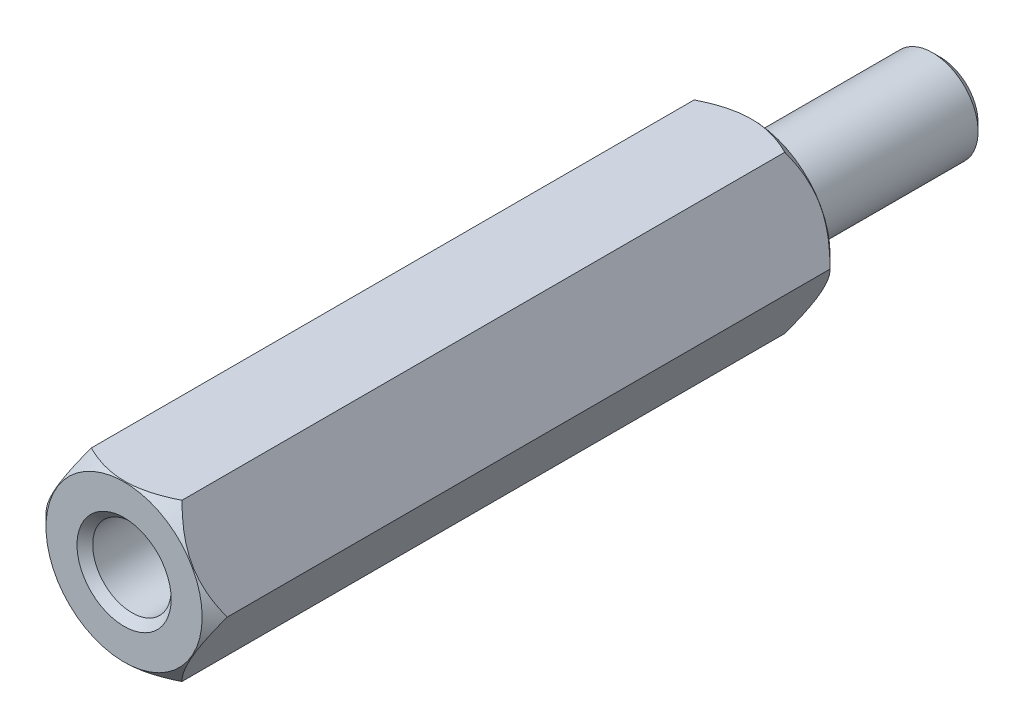
from build123d import *

# Parameters (mm, degrees)
HEX_2_DEPTH                 = 10
TAP_DRILL_FOR_M3X0_5_TAP1_D = 2.5
SKETCH8_R                   = 1.45
THREAD_DEPTH                = 6
THREAD_DEPTH_BACK           = 2
INNERCHAMFER_SIZE           = 0.25


with BuildPart() as part:
    # Sketch1 → HEX 2 (new body, symmetric)
    with BuildSketch(Plane.XY):
        Polygon((2.886751346, 0), (1.443375673, 2.5), (-1.443375673, 2.5), (-2.886751346, 0), (-1.443375673, -2.5), (1.443375673, -2.5), align=None)
    extrude(amount=HEX_2_DEPTH, both=True)

    # Tap Drill for M3x0.5 Tap1 (through all)
    with Locations(Plane.XY.offset(10)):
        with Locations((0, 0)):
            Hole(TAP_DRILL_FOR_M3X0_5_TAP1_D / 2)

    # Sketch7 → HexChamfer (revolve, cut)
    with BuildSketch(Plane(origin=(0, 0, 0), x_dir=(1, 0, 0), z_dir=(0, 1, 0))):
        Polygon((-2.886751346, 10), (-2.886751346, 9.6), (-2.486751346, 10), align=None)
    hexchamfer = revolve(axis=Axis((0, 0, 15.266742202), (0, 0, -1)), mode=Mode.SUBTRACT)

    # Mirror1: HexChamfer across plane
    add(hexchamfer.mirror(Plane.XY), mode=Mode.SUBTRACT)

    # Sketch8 → Thread (add, two sides)
    with BuildSketch(Plane(origin=(0, 0, -10), x_dir=(-1, 0, 0), z_dir=(0, 0, -1))) as thread_sk:
        Circle(SKETCH8_R)
    extrude(amount=THREAD_DEPTH)
    extrude(thread_sk.sketch, amount=-THREAD_DEPTH_BACK)

    # InnerChamfer
    innerchamfer_edges = [part.edges().sort_by_distance(p)[0] for p in [
        (1.25, 0, 10),
        (1.45, 0, -10),
        (1.45, 0, -16),
    ]]
    chamfer(innerchamfer_edges, length=INNERCHAMFER_SIZE)


solid = part.part
